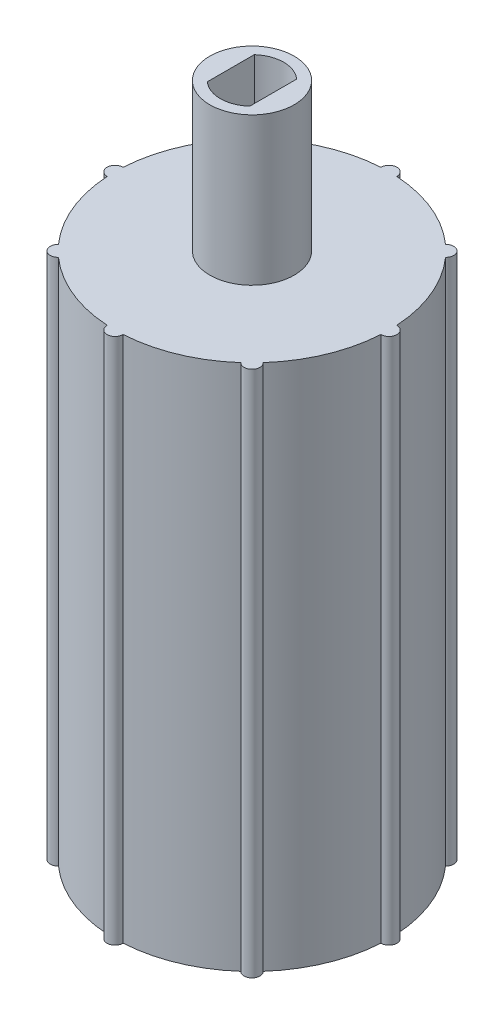
from build123d import *

# Parameters (mm, degrees)
ESQUISSE2_R                  = 13
BOSS_EXTRU_1_DEPTH           = 50
ESQUISSE3_R                  = 9
ENL_V_MAT_EXTRU_1_DEPTH      = 51
ESQUISSE4_R                  = 11
ENL_V_MAT_EXTRU_2_DEPTH      = 7
ESQUISSE6_R                  = 0.75
BOSS_EXTRU_2_DEPTH           = 50
R_P_TITION_CIRCULAIRE1_COUNT = 8
ESQUISSE7_R                  = 9
BOSS_EXTRU_3_DEPTH           = 3
ESQUISSE8_R                  = 4
BOSS_EXTRU_5_DEPTH           = 14
ENL_V_MAT_EXTRU_4_DEPTH      = 14


with BuildPart() as part:
    # Esquisse2 → Boss.-Extru.1 (new body)
    with BuildSketch(Plane(origin=(0, 0, 0), x_dir=(1, 0, 0), z_dir=(0, 1, 0))):
        Circle(ESQUISSE2_R)
    extrude(amount=BOSS_EXTRU_1_DEPTH)

    # Esquisse3 → Enlèv. mat.-Extru.1 (cut, through all)
    with BuildSketch(Plane.XZ):
        Circle(ESQUISSE3_R)
    extrude(amount=-ENL_V_MAT_EXTRU_1_DEPTH, mode=Mode.SUBTRACT)

    # Esquisse4 → Enlèv. mat.-Extru.2 (cut)
    with BuildSketch(Plane.XZ):
        Circle(ESQUISSE4_R)
    extrude(amount=-ENL_V_MAT_EXTRU_2_DEPTH, mode=Mode.SUBTRACT)

    # Esquisse6 → Boss.-Extru.2 (add)
    with BuildSketch(Plane(origin=(0, 0, 0), x_dir=(-1, 0, 0), z_dir=(0, -1, 0))):
        with Locations((-13, 0)):
            Circle(ESQUISSE6_R)
    boss_extru_2 = extrude(amount=-BOSS_EXTRU_2_DEPTH)

    # Répétition circulaire1: Boss.-Extru.2 ×8 about axis
    r_p_tition_circulaire1_axis = Axis((0, 0, 0), (0, 1, 0))
    for i in range(1, R_P_TITION_CIRCULAIRE1_COUNT):
        add(boss_extru_2.rotate(r_p_tition_circulaire1_axis, i * 360 / R_P_TITION_CIRCULAIRE1_COUNT))

    # Esquisse7 → Boss.-Extru.3 (add)
    with BuildSketch(Plane(origin=(0, 50, 0), x_dir=(1, 0, 0), z_dir=(0, 1, 0))):
        Circle(ESQUISSE7_R)
    extrude(amount=-BOSS_EXTRU_3_DEPTH)

    # Esquisse8 → Boss.-Extru.5 (add)
    with BuildSketch(Plane(origin=(0, 50, 0), x_dir=(1, 0, 0), z_dir=(0, 1, 0))):
        Circle(ESQUISSE8_R)
    extrude(amount=BOSS_EXTRU_5_DEPTH)

    # Esquisse10 → Enlèv. mat.-Extru.4 (cut)
    with BuildSketch(Plane(origin=(0, 64, 0), x_dir=(1, 0, 0), z_dir=(0, 1, 0))):
        with BuildLine():
            Line((-2.009853687, -2.227215337), (-2.009853687, 2.227215337))
            ThreePointArc((-2.009853687, 2.227215337), (0, 3), (2.009853687, 2.227215337))
            Line((2.009853687, 2.227215337), (2.009853687, -2.227215337))
            ThreePointArc((2.009853687, -2.227215337), (0, -3), (-2.009853687, -2.227215337))
        make_face()
    extrude(amount=-ENL_V_MAT_EXTRU_4_DEPTH, mode=Mode.SUBTRACT)


solid = part.part
